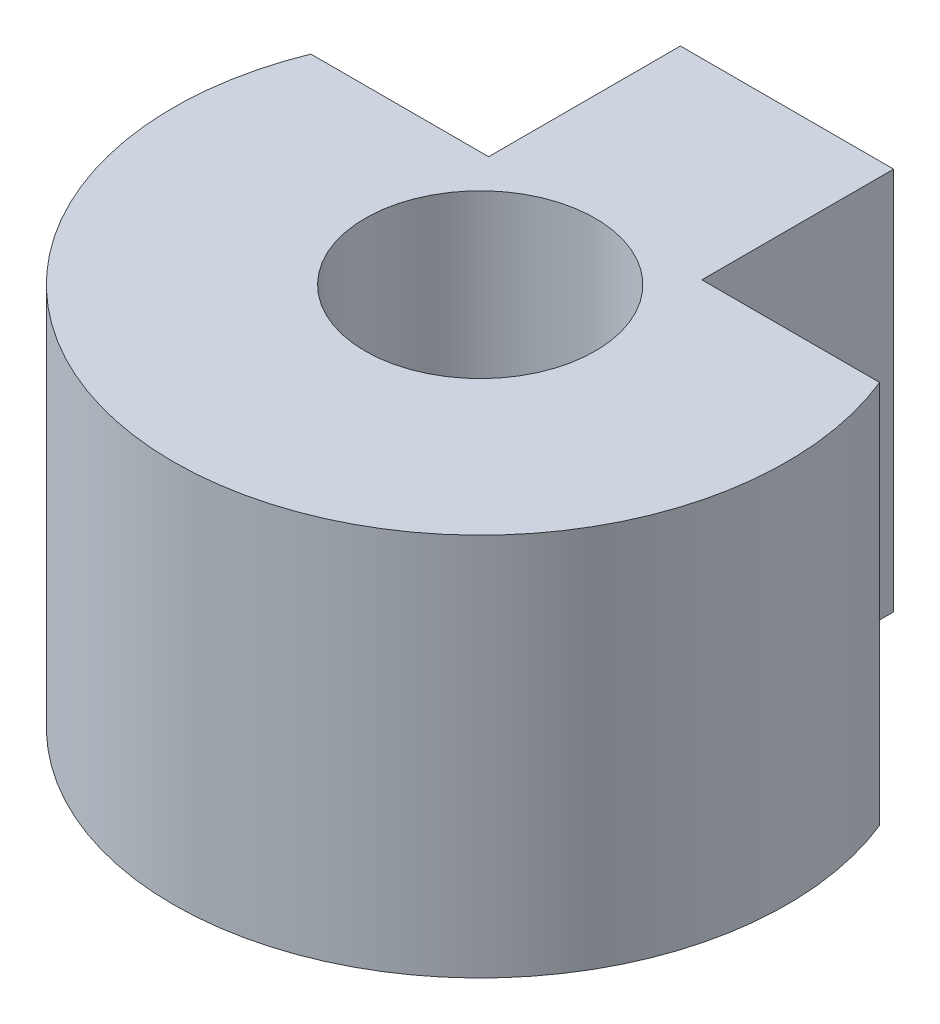
from build123d import *

# Parameters (mm, degrees)
SKETCH1_R           = 1.905
BOSS_EXTRUDE1_DEPTH = 6.35


with BuildPart() as part:
    # Sketch1 → Boss-Extrude1 (new body)
    with BuildSketch(Plane(origin=(0, 0, 0), x_dir=(1, 0, 0), z_dir=(0, 1, 0))):
        with BuildLine():
            Line((-1.7653, 1.905), (-1.7653, 5.08))
            Line((-1.7653, 5.08), (1.7653, 5.08))
            Line((1.7653, 5.08), (1.7653, 1.905))
            Line((1.7653, 1.905), (4.709286039, 1.905))
            ThreePointArc((4.709286039, 1.905), (0, -5.08), (-4.709286039, 1.905))
            Line((-4.709286039, 1.905), (-1.7653, 1.905))
        make_face()
        Circle(SKETCH1_R, mode=Mode.SUBTRACT)
    extrude(amount=BOSS_EXTRUDE1_DEPTH)


solid = part.part
